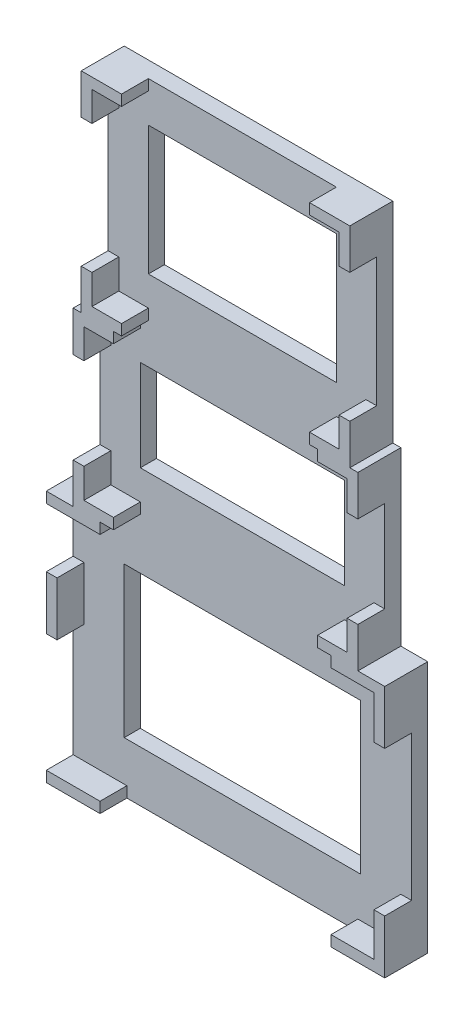
from build123d import *

# Parameters (mm, degrees)
SKETCH1_W           = 50
SKETCH1_H           = 39
BOSS_EXTRUDE1_DEPTH = 3
SKETCH2_W           = 2
SKETCH2_H           = 2
SKETCH2_H_2         = 8
SKETCH2_W_2         = 8
SKETCH2_W_3         = 10
SKETCH2_H_3         = 10
BOSS_EXTRUDE2_DEPTH = 5
SKETCH3_W           = 44
SKETCH3_H           = 28
CUT_EXTRUDE1_DEPTH  = 5
SKETCH4_W           = 2
SKETCH4_H           = 2
SKETCH4_H_2         = 5.5
SKETCH4_W_2         = 5.5
BOSS_EXTRUDE3_DEPTH = 5
SKETCH5_W           = 2
SKETCH5_H           = 5.5
SKETCH5_H_2         = 2
SKETCH5_W_2         = 5.5
BOSS_EXTRUDE4_DEPTH = 5
SKETCH6_W           = 38
SKETCH6_H           = 17
CUT_EXTRUDE2_DEPTH  = 5
SKETCH7_W           = 35
SKETCH7_H           = 24
CUT_EXTRUDE3_DEPTH  = 5


with BuildPart() as part:
    # Sketch1 → Boss-Extrude1 (new body)
    with BuildSketch(Plane.XY):
        Polygon((5, 47), (0, 47), (0, 0), (63, 0), (63, 47), (58, 47), align=None)
        Polygon((5, 79), (5, 47), (58, 47), (58, 79), (56.5, 79), (6.5, 79), align=None)
        with Locations((31.5, 98.5)):
            Rectangle(SKETCH1_W, SKETCH1_H)
    extrude(amount=BOSS_EXTRUDE1_DEPTH)

    # Sketch2 → Boss-Extrude2 (add)
    with BuildSketch(Plane.XY.offset(3)):
        Polygon((53, 45), (61, 45), (61, 47), (58, 47), (53, 47), align=None)
        with Locations((62, 46)):
            Rectangle(SKETCH2_W, SKETCH2_H)
        with Locations((62, 41)):
            Rectangle(SKETCH2_W, SKETCH2_H_2)
        with Locations((62, 6)):
            Rectangle(SKETCH2_W, SKETCH2_H_2)
        with Locations((62, 1)):
            Rectangle(SKETCH2_W, SKETCH2_H)
        with Locations((57, 1)):
            Rectangle(SKETCH2_W_2, SKETCH2_H)
        with Locations((5, 1)):
            Rectangle(SKETCH2_W_3, SKETCH2_H)
        with Locations((5, 46)):
            Rectangle(SKETCH2_W_3, SKETCH2_H)
        with Locations((1, 29)):
            Rectangle(SKETCH2_W, SKETCH2_H_3)
    extrude(amount=BOSS_EXTRUDE2_DEPTH)

    # Sketch3 → Cut-Extrude1 (cut)
    with BuildSketch(Plane.XY.offset(3)):
        with Locations((31.5, 23.5)):
            Rectangle(SKETCH3_W, SKETCH3_H)
    extrude(amount=-CUT_EXTRUDE1_DEPTH, mode=Mode.SUBTRACT)

    # Sketch4 → Boss-Extrude3 (add)
    with BuildSketch(Plane.XY.offset(3)):
        with Locations((6, 48)):
            Rectangle(SKETCH4_W, SKETCH4_H)
        with Locations((6, 51.75)):
            Rectangle(SKETCH4_W, SKETCH4_H_2)
        Polygon((7, 49), (7, 47), (10, 47), (12.5, 47), (12.5, 49), align=None)
        with Locations((6, 74.25)):
            Rectangle(SKETCH4_W, SKETCH4_H_2)
        Polygon((5, 79), (5, 77), (7, 77), (7, 79), (6.5, 79), align=None)
        with Locations((9.75, 78)):
            Rectangle(SKETCH4_W_2, SKETCH4_H)
        with Locations((53.25, 78)):
            Rectangle(SKETCH4_W_2, SKETCH4_H)
        Polygon((56, 77), (58, 77), (58, 79), (56.5, 79), (56, 79), align=None)
        with Locations((57, 74.25)):
            Rectangle(SKETCH4_W, SKETCH4_H_2)
        with Locations((57, 51.75)):
            Rectangle(SKETCH4_W, SKETCH4_H_2)
        with Locations((57, 48)):
            Rectangle(SKETCH4_W, SKETCH4_H)
        Polygon((53, 47), (56, 47), (56, 49), (50.5, 49), (50.5, 47), align=None)
    extrude(amount=BOSS_EXTRUDE3_DEPTH)

    # Sketch5 → Boss-Extrude4 (add)
    with BuildSketch(Plane.XY.offset(3)):
        with Locations((7.5, 83.75)):
            Rectangle(SKETCH5_W, SKETCH5_H)
        Polygon((8.5, 81), (8.5, 79), (12.5, 79), (14, 79), (14, 81), align=None)
        with Locations((7.5, 80)):
            Rectangle(SKETCH5_W, SKETCH5_H_2)
        Polygon((54.5, 79), (54.5, 81), (49, 81), (49, 79), (50.5, 79), align=None)
        with Locations((55.5, 80)):
            Rectangle(SKETCH5_W, SKETCH5_H_2)
        with Locations((55.5, 83.75)):
            Rectangle(SKETCH5_W, SKETCH5_H)
        with Locations((51.75, 117)):
            Rectangle(SKETCH5_W_2, SKETCH5_H_2)
        with Locations((55.5, 117)):
            Rectangle(SKETCH5_W, SKETCH5_H_2)
        with Locations((55.5, 113.25)):
            Rectangle(SKETCH5_W, SKETCH5_H)
        with Locations((11.25, 117)):
            Rectangle(SKETCH5_W_2, SKETCH5_H_2)
        with Locations((7.5, 117)):
            Rectangle(SKETCH5_W, SKETCH5_H_2)
        with Locations((7.5, 113.25)):
            Rectangle(SKETCH5_W, SKETCH5_H)
    extrude(amount=BOSS_EXTRUDE4_DEPTH)

    # Sketch6 → Cut-Extrude2 (cut)
    with BuildSketch(Plane.XY.offset(3)):
        with Locations((31.5, 63)):
            Rectangle(SKETCH6_W, SKETCH6_H)
    extrude(amount=-CUT_EXTRUDE2_DEPTH, mode=Mode.SUBTRACT)

    # Sketch7 → Cut-Extrude3 (cut)
    with BuildSketch(Plane.XY.offset(3)):
        with Locations((31.5, 98.5)):
            Rectangle(SKETCH7_W, SKETCH7_H)
    extrude(amount=-CUT_EXTRUDE3_DEPTH, mode=Mode.SUBTRACT)


solid = part.part
